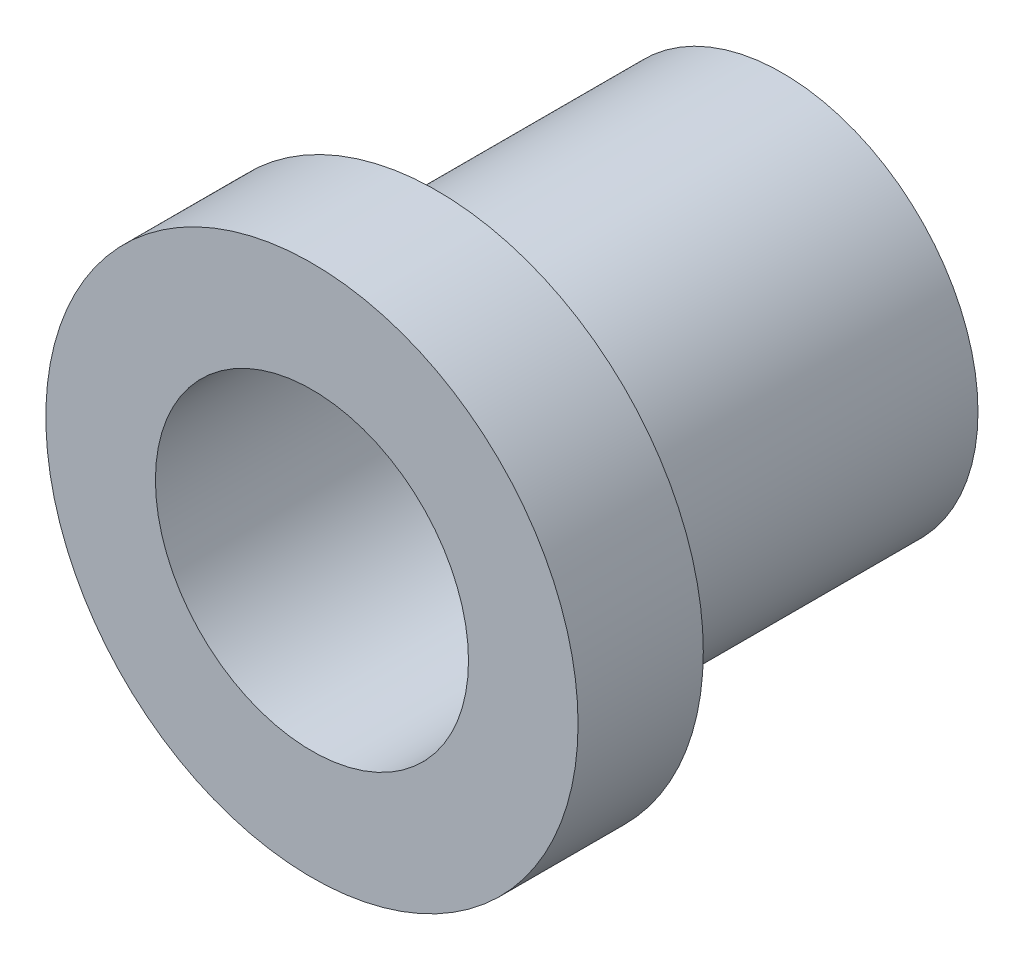
from build123d import *

# Parameters (mm, degrees)
SKETCH1_R           = 5.3975
SKETCH1_R_2         = 3.175
BOSS_EXTRUDE1_DEPTH = 2.54
SKETCH2_R           = 3.96875
SKETCH2_R_2         = 3.175
BOSS_EXTRUDE2_DEPTH = 7


with BuildPart() as part:
    # Sketch1 → Boss-Extrude1 (new body)
    with BuildSketch(Plane.XY):
        Circle(SKETCH1_R)
        Circle(SKETCH1_R_2, mode=Mode.SUBTRACT)
    extrude(amount=BOSS_EXTRUDE1_DEPTH)

    # Sketch2 → Boss-Extrude2 (add)
    with BuildSketch(Plane(origin=(0, 0, 0), x_dir=(-1, 0, 0), z_dir=(0, 0, -1))):
        Circle(SKETCH2_R)
        Circle(SKETCH2_R_2, mode=Mode.SUBTRACT)
    extrude(amount=BOSS_EXTRUDE2_DEPTH)


solid = part.part
